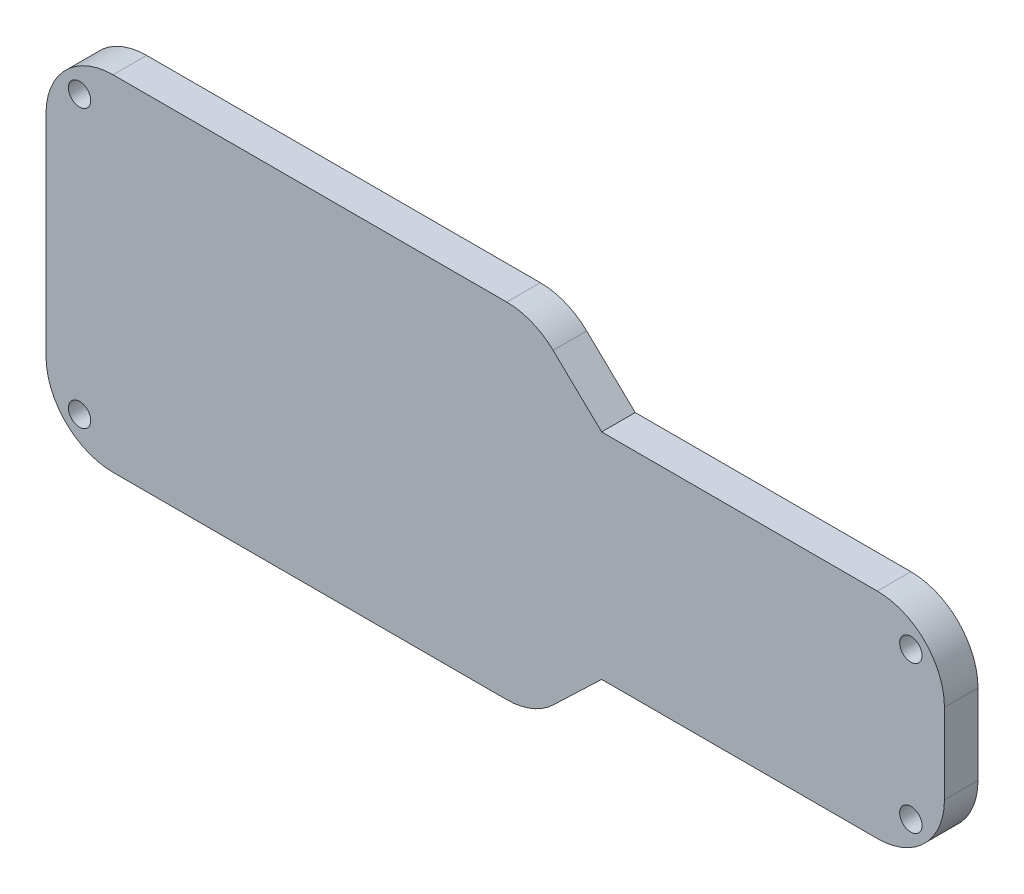
from build123d import *

# Parameters (mm, degrees)
SKETCH3_R           = 1
BOSS_EXTRUDE2_DEPTH = 3
BOSS_EXTRUDE5_DEPTH = 3


with BuildPart() as part:
    # Sketch3 → Boss-Extrude2 (new body)
    with BuildSketch(Plane.XY):
        with BuildLine():
            Line((-69.81, 20.47), (-34.625063383, 20.47))
            ThreePointArc((-34.625063383, 20.47), (-32.391172348, 20.03863815), (-30.478486436, 18.806576947))
            Line((-30.478486436, 18.806576947), (-26.141909489, 14.66))
            Line((-26.141909489, 14.66), (-1.5, 14.66))
            ThreePointArc((-1.5, 14.66), (2.742640687, 12.902640687), (4.5, 8.66))
            Line((4.5, 8.66), (4.5, 1.5))
            ThreePointArc((4.5, 1.5), (2.742640687, -2.742640687), (-1.5, -4.5))
            Line((-1.5, -4.5), (-26.141909489, -4.5))
            Line((-26.141909489, -4.5), (-30.478486436, -8.646576947))
            ThreePointArc((-30.478486436, -8.646576947), (-32.391172348, -9.87863815), (-34.625063383, -10.31))
            Line((-34.625063383, -10.31), (-69.81, -10.31))
            ThreePointArc((-69.81, -10.31), (-74.052640687, -8.552640687), (-75.81, -4.31))
            Line((-75.81, -4.31), (-75.81, 14.47))
            ThreePointArc((-75.81, 14.47), (-74.052640687, 18.712640687), (-69.81, 20.47))
        make_face()
        with Locations((-72.81, 17.47)):
            Circle(SKETCH3_R, mode=Mode.SUBTRACT)
        with Locations((-72.81, -7.31)):
            Circle(SKETCH3_R, mode=Mode.SUBTRACT)
        with Locations((1.5, -1.5)):
            Circle(SKETCH3_R, mode=Mode.SUBTRACT)
        with Locations((1.5, 11.66)):
            Circle(SKETCH3_R, mode=Mode.SUBTRACT)
        with BuildLine():
            Line((-69.81, 17.47), (-34.625063383, 17.47))
            ThreePointArc((-34.625063383, 17.47), (-33.508117866, 17.254319075), (-32.55177491, 16.638288474))
            Line((-32.55177491, 16.638288474), (-28.215197962, 12.491711526))
            ThreePointArc((-28.215197962, 12.491711526), (-27.258855006, 11.875680925), (-26.141909489, 11.66))
            Line((-26.141909489, 11.66), (-1.5, 11.66))
            ThreePointArc((-1.5, 11.66), (0.621320344, 10.781320344), (1.5, 8.66))
            Line((1.5, 8.66), (1.5, 1.5))
            ThreePointArc((1.5, 1.5), (0.621320344, -0.621320344), (-1.5, -1.5))
            Line((-1.5, -1.5), (-26.141909489, -1.5))
            ThreePointArc((-26.141909489, -1.5), (-27.258855006, -1.715680925), (-28.215197962, -2.331711526))
            Line((-28.215197962, -2.331711526), (-32.55177491, -6.478288474))
            ThreePointArc((-32.55177491, -6.478288474), (-33.508117866, -7.094319075), (-34.625063383, -7.31))
            Line((-34.625063383, -7.31), (-69.81, -7.31))
            ThreePointArc((-69.81, -7.31), (-71.931320344, -6.431320344), (-72.81, -4.31))
            Line((-72.81, -4.31), (-72.81, 14.47))
            ThreePointArc((-72.81, 14.47), (-71.931320344, 16.591320344), (-69.81, 17.47))
        make_face(mode=Mode.SUBTRACT)
    extrude(amount=BOSS_EXTRUDE2_DEPTH)

    # Sketch8 → Boss-Extrude5 (add)
    with BuildSketch(Plane.XY.offset(3)):
        with BuildLine():
            Line((-72.81, 14.47), (-72.81, -4.31))
            ThreePointArc((-72.81, -4.31), (-71.931320344, -6.431320344), (-69.81, -7.31))
            Line((-69.81, -7.31), (-34.625063383, -7.31))
            ThreePointArc((-34.625063383, -7.31), (-33.508117866, -7.094319075), (-32.55177491, -6.478288474))
            Line((-32.55177491, -6.478288474), (-28.215197962, -2.331711526))
            ThreePointArc((-28.215197962, -2.331711526), (-27.258855006, -1.715680925), (-26.141909489, -1.5))
            Line((-26.141909489, -1.5), (-1.5, -1.5))
            ThreePointArc((-1.5, -1.5), (0.621320344, -0.621320344), (1.5, 1.5))
            Line((1.5, 1.5), (1.5, 8.66))
            ThreePointArc((1.5, 8.66), (0.621320344, 10.781320344), (-1.5, 11.66))
            Line((-1.5, 11.66), (-26.141909489, 11.66))
            ThreePointArc((-26.141909489, 11.66), (-27.258855006, 11.875680925), (-28.215197962, 12.491711526))
            Line((-28.215197962, 12.491711526), (-32.55177491, 16.638288474))
            ThreePointArc((-32.55177491, 16.638288474), (-33.508117866, 17.254319075), (-34.625063383, 17.47))
            Line((-34.625063383, 17.47), (-69.81, 17.47))
            ThreePointArc((-69.81, 17.47), (-71.931320344, 16.591320344), (-72.81, 14.47))
        make_face()
    extrude(amount=-BOSS_EXTRUDE5_DEPTH)


solid = part.part
